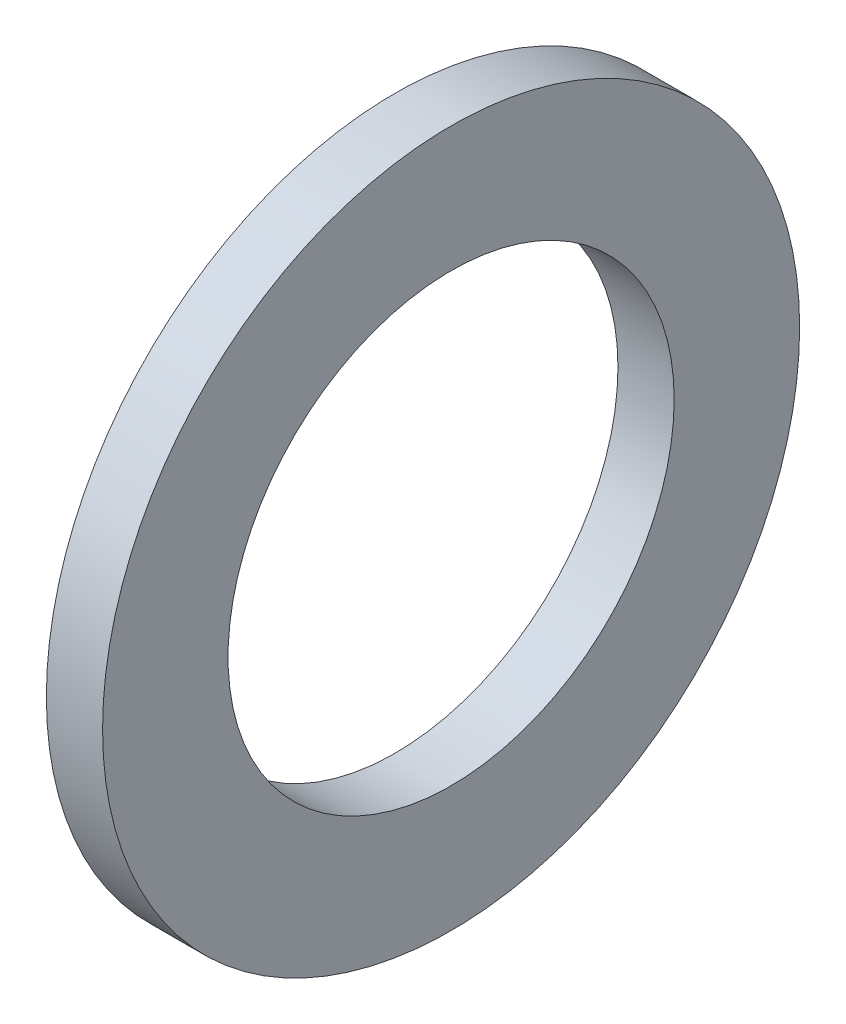
from build123d import *

# Parameters (mm, degrees)
SKETCH1_R      = 19.84375
SKETCH1_R_2    = 12.7
EXTRUDE1_DEPTH = 3.2004


with BuildPart() as part:
    # Sketch1 → Extrude1 (new body)
    with BuildSketch(Plane(origin=(0, 0, 0), x_dir=(0, 0, -1), z_dir=(1, 0, 0))):
        Circle(SKETCH1_R)
        Circle(SKETCH1_R_2, mode=Mode.SUBTRACT)
    extrude(amount=EXTRUDE1_DEPTH)


solid = part.part
